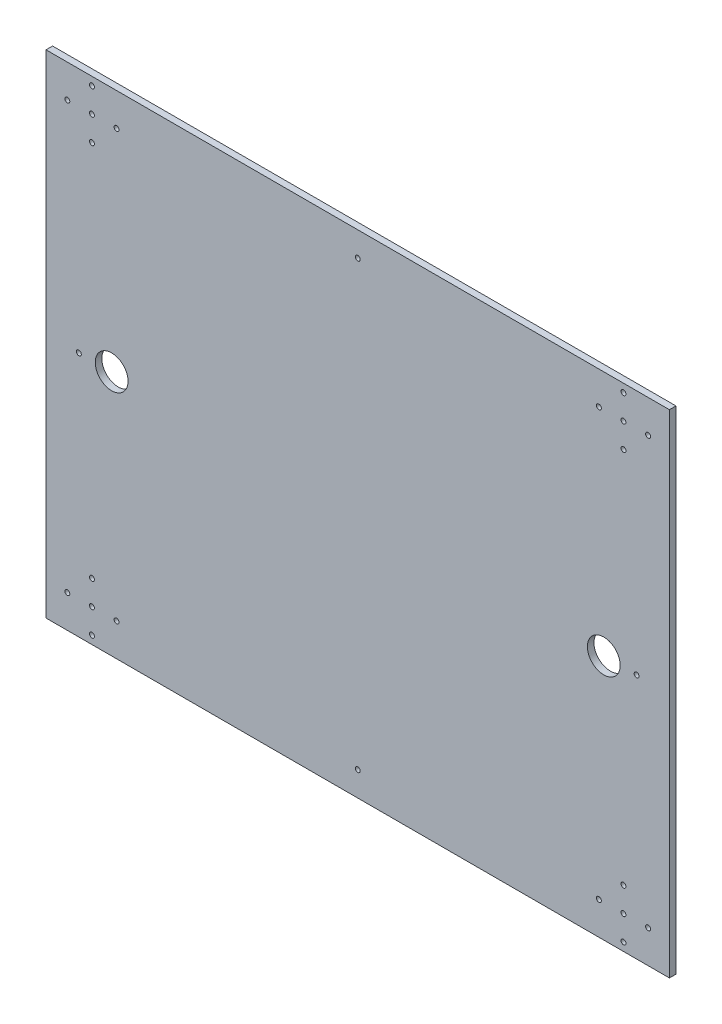
from build123d import *

# Parameters (mm, degrees)
SKETCH3_W           = 380
SKETCH3_H           = 300
BOSS_EXTRUDE1_DEPTH = 4
HOLE2_D             = 20
HOLE2_DEPTH         = 100
SKETCH10_R          = 1.5
CUT_EXTRUDE1_DEPTH  = 4
SKETCH11_R          = 1.5
CUT_EXTRUDE2_DEPTH  = 4


with BuildPart() as part:
    # Sketch3 → Boss-Extrude1 (new body)
    with BuildSketch(Plane.XY):
        with Locations((-123.149881766, 47.763665148)):
            Rectangle(SKETCH3_W, SKETCH3_H)
    extrude(amount=BOSS_EXTRUDE1_DEPTH)

    # Hole2
    with Locations(Plane(origin=(-273.149881766, 47.763665148, 4), x_dir=(1, 0, 0), z_dir=(0, 0, 1))):
        with Locations((0, 0), (300, 0)):
            Hole(HOLE2_D / 2, depth=HOLE2_DEPTH)

    # Sketch10 → Cut-Extrude1 (cut)
    with BuildSketch(Plane(origin=(0, 0, 0), x_dir=(-1, 0, 0), z_dir=(0, 0, -1))):
        with Locations((285.149881766, 177.763665148)):
            Circle(SKETCH10_R)
        with Locations((270.149881766, 177.763665148)):
            Circle(SKETCH10_R)
        with Locations((285.149881766, 192.763665148)):
            Circle(SKETCH10_R)
        with Locations((300.149881766, 177.763665148)):
            Circle(SKETCH10_R)
        with Locations((285.149881766, 162.763665148)):
            Circle(SKETCH10_R)
        with Locations((-38.850118234, 162.763665148)):
            Circle(SKETCH10_R)
        with Locations((-53.850118234, 177.763665148)):
            Circle(SKETCH10_R)
        with Locations((-38.850118234, 177.763665148)):
            Circle(SKETCH10_R)
        with Locations((-38.850118234, 192.763665148)):
            Circle(SKETCH10_R)
        with Locations((-23.850118234, 177.763665148)):
            Circle(SKETCH10_R)
        with Locations((-38.850118234, -97.236334852)):
            Circle(SKETCH10_R)
        with Locations((-53.850118234, -82.236334852)):
            Circle(SKETCH10_R)
        with Locations((-38.850118234, -82.236334852)):
            Circle(SKETCH10_R)
        with Locations((-38.850118234, -67.236334852)):
            Circle(SKETCH10_R)
        with Locations((-23.850118234, -82.236334852)):
            Circle(SKETCH10_R)
        with Locations((285.149881766, -97.236334852)):
            Circle(SKETCH10_R)
        with Locations((270.149881766, -82.236334852)):
            Circle(SKETCH10_R)
        with Locations((285.149881766, -82.236334852)):
            Circle(SKETCH10_R)
        with Locations((285.149881766, -67.236334852)):
            Circle(SKETCH10_R)
        with Locations((300.149881766, -82.236334852)):
            Circle(SKETCH10_R)
    extrude(amount=-CUT_EXTRUDE1_DEPTH, mode=Mode.SUBTRACT)

    # Sketch11 → Cut-Extrude2 (cut)
    with BuildSketch(Plane(origin=(0, 0, 0), x_dir=(-1, 0, 0), z_dir=(0, 0, -1))):
        with Locations((293.149881766, 47.763665148)):
            Circle(SKETCH11_R)
        with Locations((123.149881766, 182.763665148)):
            Circle(SKETCH11_R)
        with Locations((-46.850118234, 47.763665148)):
            Circle(SKETCH11_R)
        with Locations((123.149881766, -87.236334852)):
            Circle(SKETCH11_R)
    extrude(amount=-CUT_EXTRUDE2_DEPTH, mode=Mode.SUBTRACT)


solid = part.part
